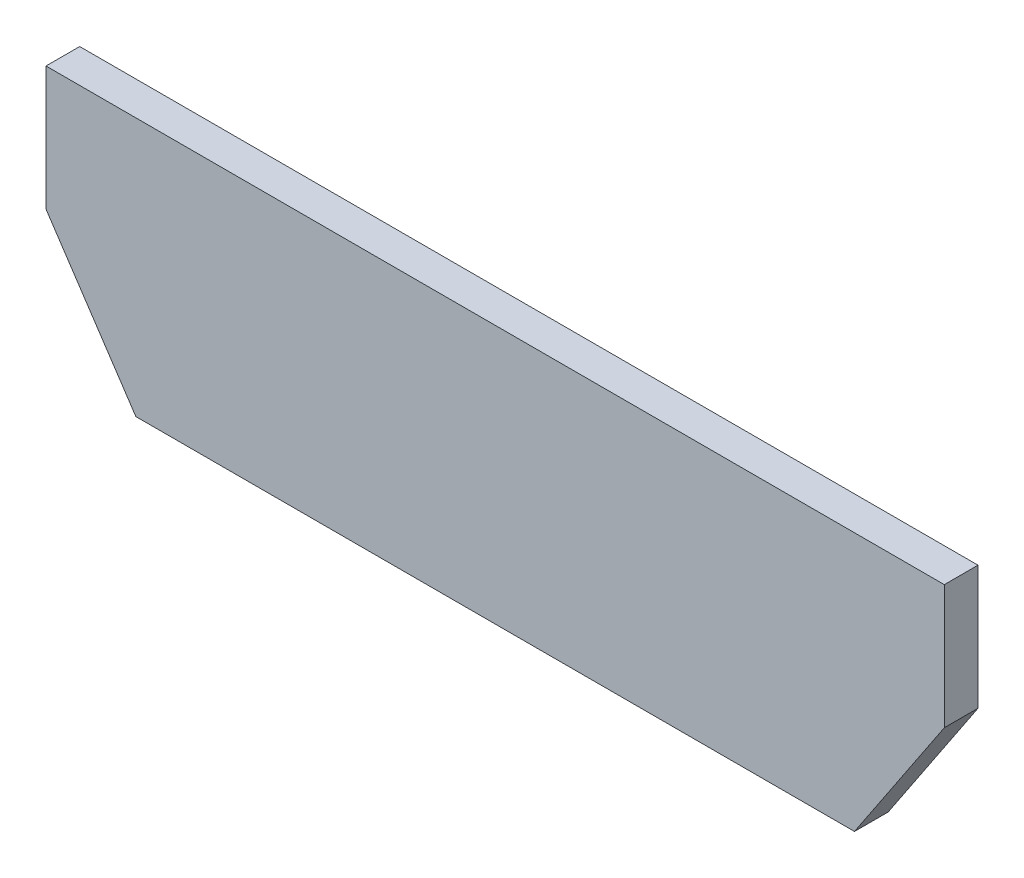
from build123d import *

# Parameters (mm, degrees)
BOSS_EXTRUDE1_DEPTH = 4.7625


with BuildPart() as part:
    # Sketch1 → Boss-Extrude1 (new body)
    with BuildSketch(Plane.XY):
        Polygon((123.825, 2.286), (136.525, 21.336), (136.525, 38.862), (9.525, 38.862), (9.525, 21.336), (22.225, 2.286), align=None)
    extrude(amount=BOSS_EXTRUDE1_DEPTH)


solid = part.part
